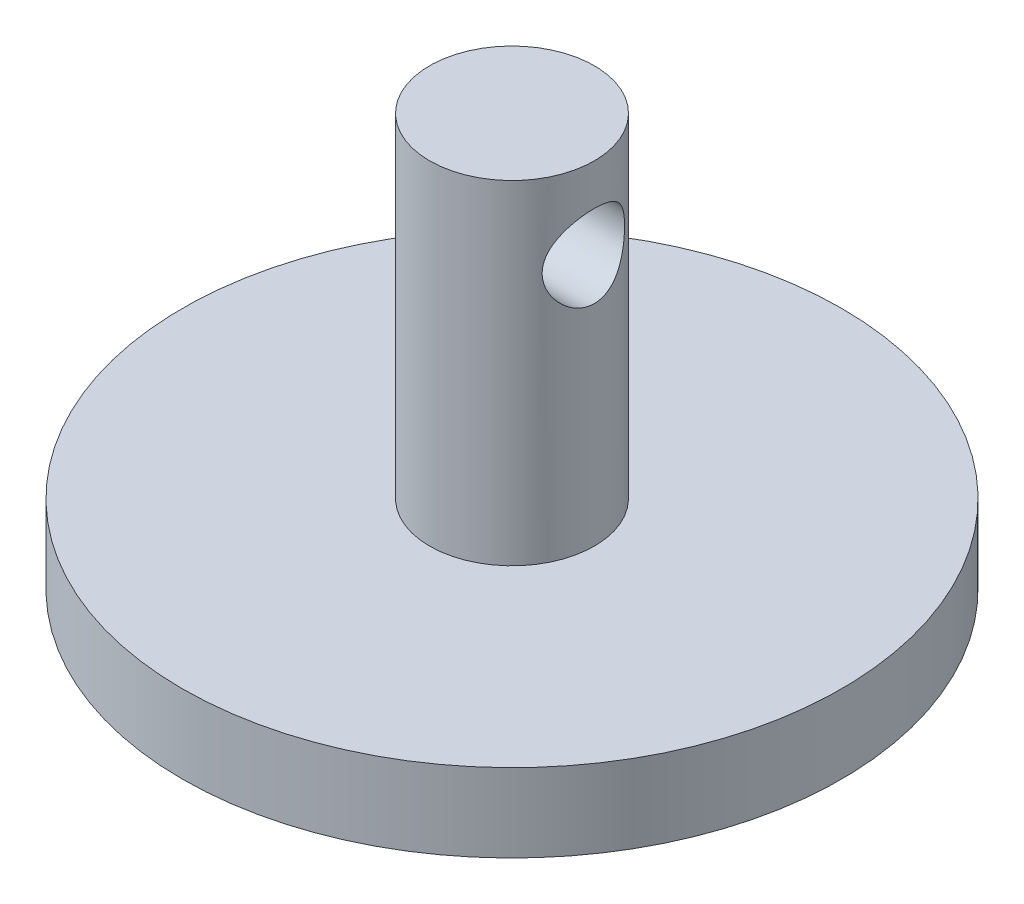
from build123d import *

# Parameters (mm, degrees)
SKETCH2_R               = 1
CUT_EXTRUDE1_DEPTH      = 9
CUT_EXTRUDE1_DEPTH_BACK = 9


with BuildPart() as part:
    # Sketch1 → Revolve1 (revolve)
    with BuildSketch(Plane(origin=(0, 0, 0), x_dir=(0, 0, -1), z_dir=(1, 0, 0))):
        Polygon((0, 0), (-8, 0), (-8, 1.9), (-2, 1.9), (-2, 10), (0, 10), align=None)
    revolve(axis=Axis((0, 10, 0), (0, -1, 0)))

    # Sketch2 → Cut-Extrude1 (cut, two sides)
    with BuildSketch(Plane(origin=(0, 0, 0), x_dir=(0, 0, -1), z_dir=(1, 0, 0))) as cut_extrude1_sk:
        with Locations((0, 8)):
            Circle(SKETCH2_R)
    extrude(amount=CUT_EXTRUDE1_DEPTH, mode=Mode.SUBTRACT)
    extrude(cut_extrude1_sk.sketch, amount=-CUT_EXTRUDE1_DEPTH_BACK, mode=Mode.SUBTRACT)


solid = part.part
